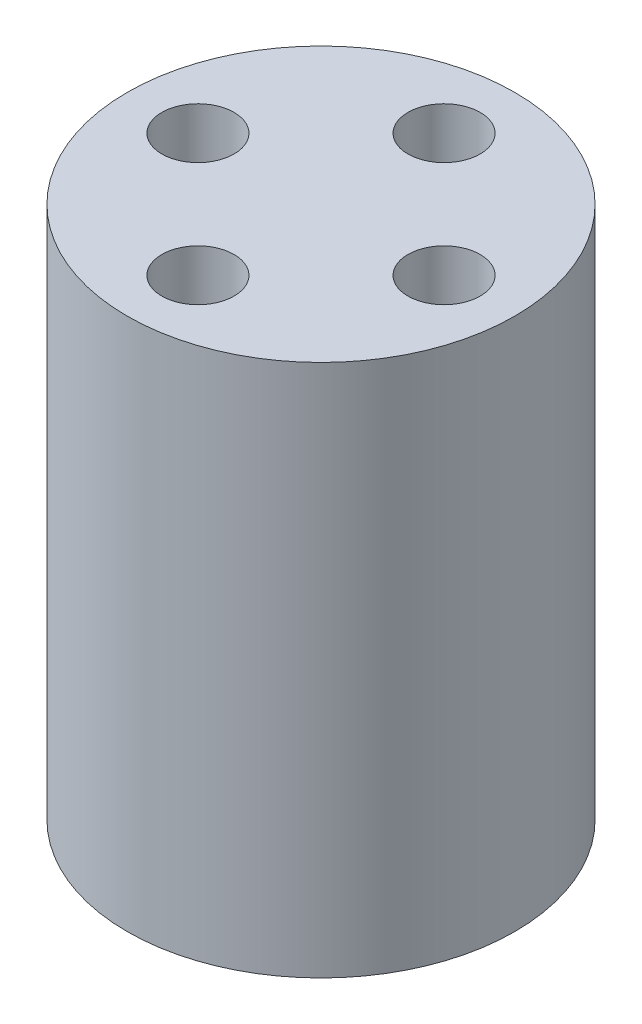
from build123d import *

# Parameters (mm, degrees)
SKETCH2_R           = 7.5
BOSS_EXTRUDE1_DEPTH = 10.31494
SKETCH3_R           = 1.397
CUT_EXTRUDE1_DEPTH  = 15.795201492
CIRPATTERN1_COUNT   = 4


with BuildPart() as part:
    # Sketch2 → Boss-Extrude1 (new, symmetric)
    with BuildSketch(Plane(origin=(0, 0, 0), x_dir=(1, 0, 0), z_dir=(0, 1, 0))):
        Circle(SKETCH2_R)
    extrude(amount=BOSS_EXTRUDE1_DEPTH, both=True)

    # Sketch3 → Cut-Extrude1 (cut, symmetric)
    with BuildSketch(Plane(origin=(0, 0, 0), x_dir=(1, 0, 0), z_dir=(0, 1, 0))):
        with Locations((0, 4.7625)):
            Circle(SKETCH3_R)
    cut_extrude1 = extrude(amount=CUT_EXTRUDE1_DEPTH, both=True, mode=Mode.SUBTRACT)

    # CirPattern1: Cut-Extrude1 ×4 about axis
    cirpattern1_axis = Axis((0, 11.346434, 0), (0, -1, 0))
    for i in range(1, CIRPATTERN1_COUNT):
        add(cut_extrude1.rotate(cirpattern1_axis, i * 360 / CIRPATTERN1_COUNT), mode=Mode.SUBTRACT)


solid = part.part
